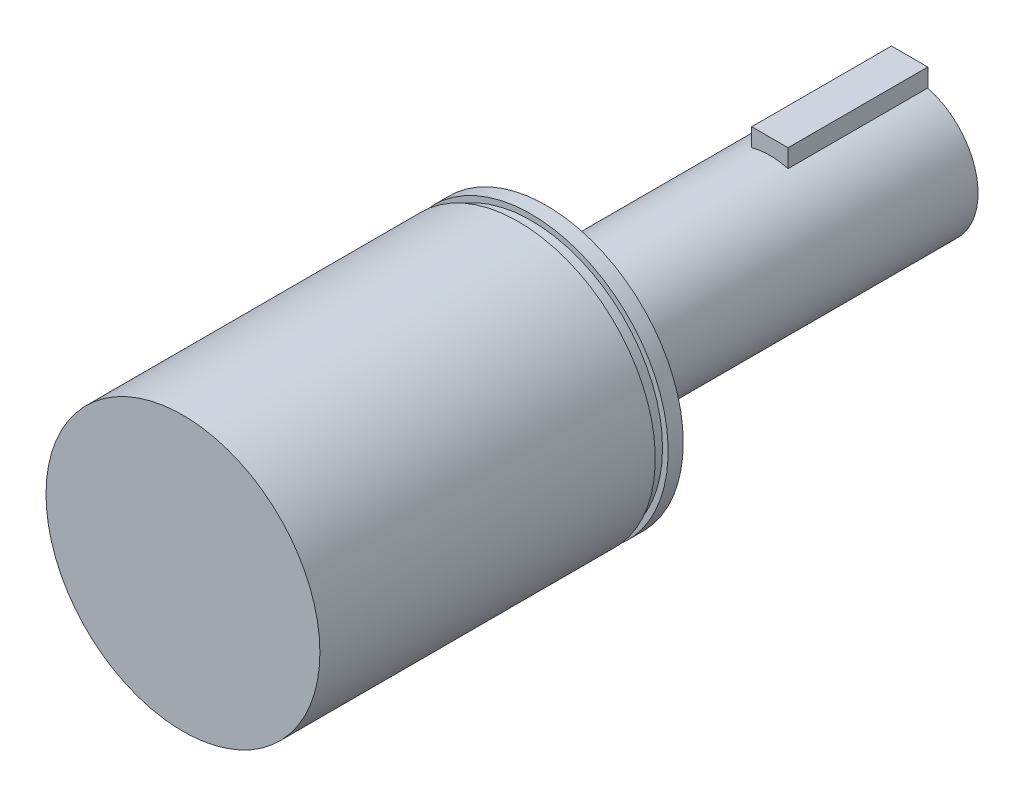
from build123d import *

# Parameters (mm, degrees)
SKETCH1_R           = 6.223
BOSS_EXTRUDE1_DEPTH = 33.02
SKETCH2_R           = 12.446
BOSS_EXTRUDE2_DEPTH = 33.02
SKETCH3_W           = 3.302
SKETCH3_H           = 3.302
BOSS_EXTRUDE3_DEPTH = 12.7
SKETCH4_R           = 11.938
CUT_EXTRUDE1_DEPTH  = 1.1684


with BuildPart() as part:
    # Sketch1 → Boss-Extrude1 (new body)
    with BuildSketch(Plane.XY):
        Circle(SKETCH1_R)
    extrude(amount=BOSS_EXTRUDE1_DEPTH)

    # Sketch2 → Boss-Extrude2 (add)
    with BuildSketch(Plane.XY.offset(33.02)):
        Circle(SKETCH2_R)
    extrude(amount=BOSS_EXTRUDE2_DEPTH)

    # Sketch3 → Boss-Extrude3 (add)
    with BuildSketch(Plane(origin=(0, 0, 0), x_dir=(-1, 0, 0), z_dir=(0, 0, -1))):
        with Locations((0, 5.999994)):
            Rectangle(SKETCH3_W, SKETCH3_H)
    extrude(amount=-BOSS_EXTRUDE3_DEPTH)

    # Sketch4 → Cut-Extrude1 (cut)
    with BuildSketch(Plane.XY.offset(35.56)):
        Polygon((-17.203352379, 15.291868781), (-17.203352379, -16.384145123), (20.97667065, -17.277825766), (19.785096459, 16.68203867), align=None)
        Circle(SKETCH4_R, mode=Mode.SUBTRACT)
    extrude(amount=-CUT_EXTRUDE1_DEPTH, mode=Mode.SUBTRACT)


solid = part.part
